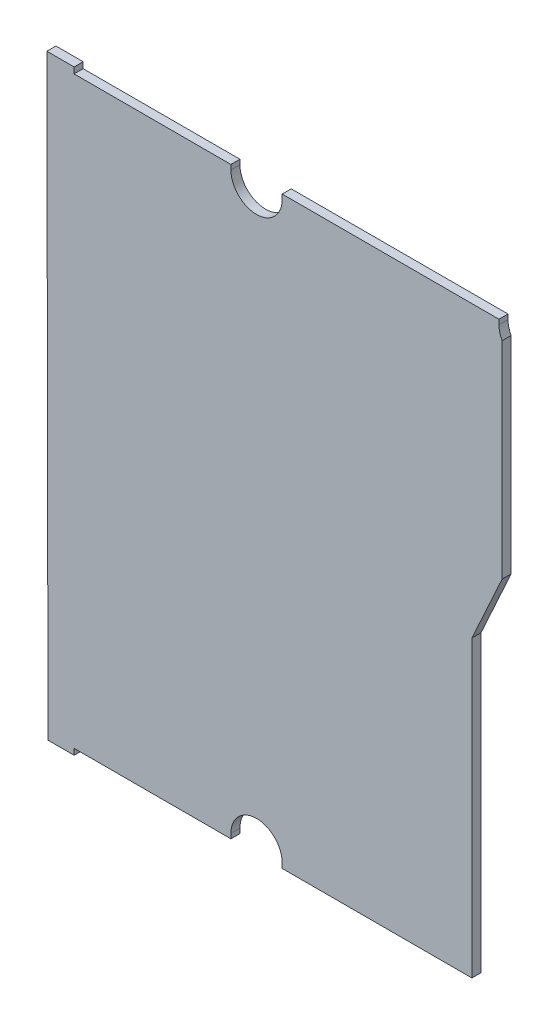
from build123d import *

# Parameters (mm, degrees)
BOSS_EXTRUDE1_DEPTH = 1.5


with BuildPart() as part:
    # Sketch1 → Boss-Extrude1 (new body)
    with BuildSketch(Plane.XY):
        with BuildLine():
            Line((-66.795, -49.425), (-66.9813, 49.425))
            Line((-66.9813, 49.425), (-62.4676, 49.425))
            Line((-62.4676, 49.425), (-62.4676, 48.425))
            Line((-62.4676, 48.425), (-36.4676, 48.425))
            Line((-36.4676, 48.425), (-36.4676, 47.625))
            ThreePointArc((-36.4676, 47.625), (-32.215, 43.3724), (-27.9624, 47.625))
            Line((-27.9624, 47.625), (-27.9624, 48.425))
            Line((-27.9624, 48.425), (7.9824, 48.425))
            Line((7.9824, 48.425), (7.9824, 47.625))
            ThreePointArc((7.9824, 47.625), (8.113831006, 46.575918078), (8.5, 45.591682081))
            Line((8.5, 45.591682081), (8.5, 11.344715994))
            Line((8.5, 11.344715994), (3.5, 0.401446139))
            Line((3.5, 0.401446139), (3.5, -48.425))
            Line((3.5, -48.425), (-27.9624, -48.425))
            Line((-27.9624, -48.425), (-27.9624, -47.625))
            ThreePointArc((-27.9624, -47.625), (-32.215, -43.3724), (-36.4676, -47.625))
            Line((-36.4676, -47.625), (-36.4676, -48.425))
            Line((-36.4676, -48.425), (-62.4676, -48.425))
            Line((-62.4676, -48.425), (-62.4676, -49.425))
            Line((-62.4676, -49.425), (-66.795, -49.425))
        make_face()
    extrude(amount=BOSS_EXTRUDE1_DEPTH)


solid = part.part
